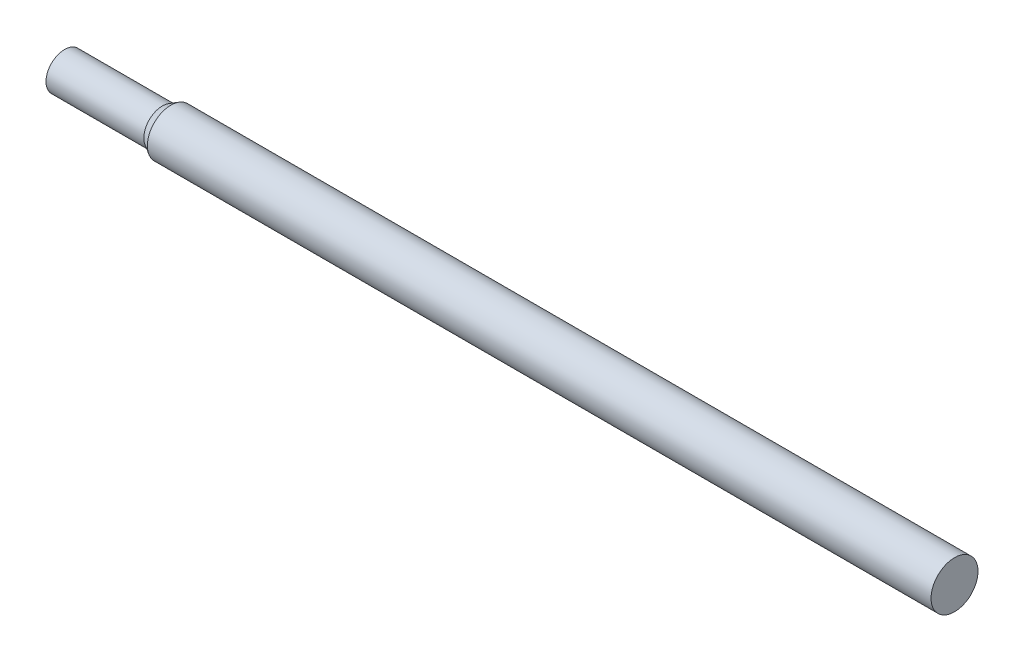
from build123d import *

# Parameters (mm, degrees)
SKETCH_3_R      = 24
EXTRUDE_2_DEPTH = 910


with BuildPart() as part:
    # 草图3 → 凸台-拉伸2 (new body)
    with BuildSketch(Plane(origin=(0, 0, 0), x_dir=(0, 0, -1), z_dir=(1, 0, 0))):
        Circle(SKETCH_3_R)
    extrude(amount=EXTRUDE_2_DEPTH)

    # 草图4 → 切除-旋转1 (revolve, cut)
    with BuildSketch(Plane(origin=(0, 0, 0), x_dir=(1, 0, 0), z_dir=(0, 1, 0))):
        Polygon((0, 24), (0, 19), (100, 19), (108.660254038, 24), align=None)
    revolve(axis=Axis((0, 0, 0), (1, 0, 0)), mode=Mode.SUBTRACT)


solid = part.part
